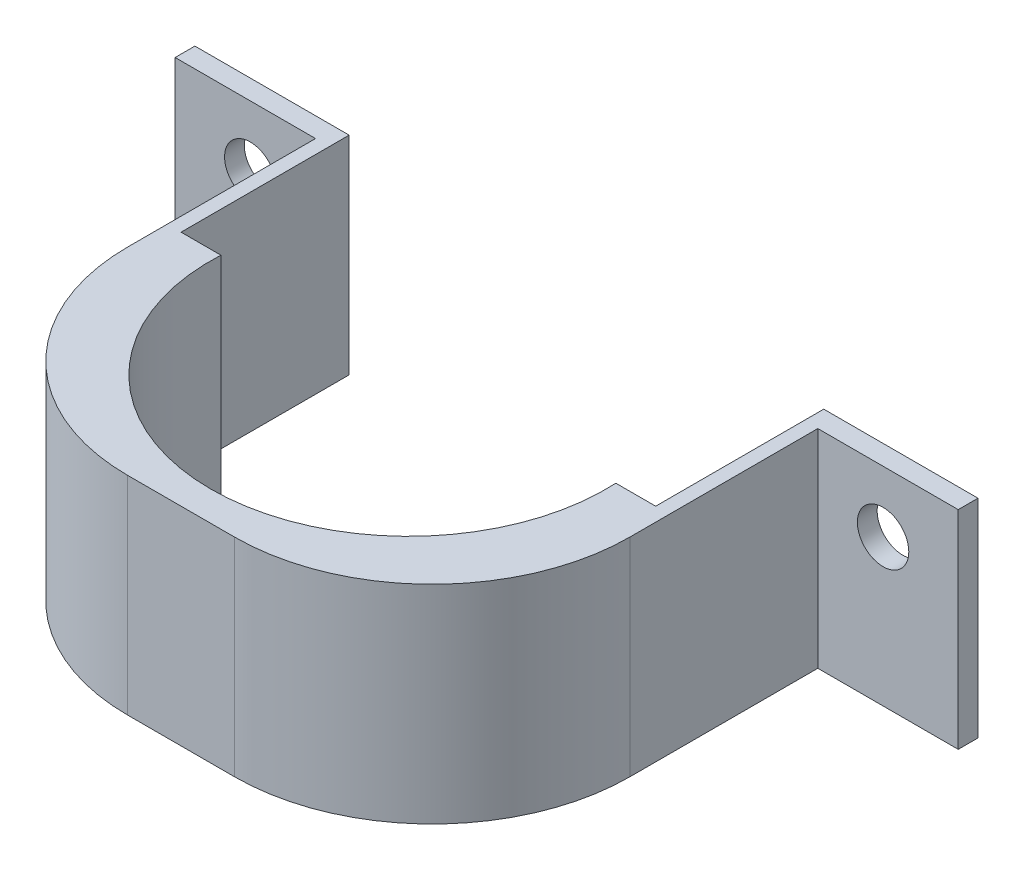
from build123d import *

# Parameters (mm, degrees)
SKETCH1_W           = 100.584
SKETCH1_H           = 26.67
SKETCH1_R           = 3.302
BOSS_EXTRUDE1_DEPTH = 2.54
SKETCH2_W           = 64.516
SKETCH2_H           = 26.67
BOSS_EXTRUDE2_DEPTH = 49.53
CUT_EXTRUDE1_REACH  = 28.67
FILLET1_R           = 25.4


with BuildPart() as part:
    # Sketch1 → Boss-Extrude1 (new body)
    with BuildSketch(Plane.XY):
        with Locations((-0.466217893, 3.598360719)):
            Rectangle(SKETCH1_W, SKETCH1_H)
        with Locations((-41.106217893, 9.059360719)):
            Circle(SKETCH1_R, mode=Mode.SUBTRACT)
        with Locations((40.173782107, 9.059360719)):
            Circle(SKETCH1_R, mode=Mode.SUBTRACT)
    extrude(amount=BOSS_EXTRUDE1_DEPTH)

    # Sketch2 → Boss-Extrude2 (add)
    with BuildSketch(Plane.XY.offset(2.54)):
        with Locations((-0.466217893, 3.598360719)):
            Rectangle(SKETCH2_W, SKETCH2_H)
    extrude(amount=BOSS_EXTRUDE2_DEPTH)

    # Sketch5 → Cut-Extrude1 (cut, up to next)
    with BuildSketch(Plane.XZ.offset(9.736639281), mode=Mode.PRIVATE) as cut_extrude1_sk1:
        with BuildLine():
            ThreePointArc((24.933782107, 22.86), (-1.101416548, 48.252056291), (-25.834448025, 21.59))
            Line((-25.834448025, 21.59), (24.902012238, 21.59))
            ThreePointArc((24.902012238, 21.59), (24.925838398, 22.224801345), (24.933782107, 22.86))
        make_face()
    cut_extrude1_tool1 = extrude(cut_extrude1_sk1.sketch, amount=-CUT_EXTRUDE1_REACH, mode=Mode.PRIVATE) & part.part
    add(cut_extrude1_tool1.solids().sort_by_distance((-0.466218, -9.736639, 32.957158))[0], mode=Mode.SUBTRACT)
    # Sketch5 → Cut-Extrude1 (cut, up to next)
    with BuildSketch(Plane.XZ.offset(9.736639281), mode=Mode.PRIVATE) as cut_extrude1_sk2:
        with BuildLine():
            ThreePointArc((-25.834448025, 21.59), (-21.643974867, 8.836355339), (-11.53782121, 0))
            Line((-11.53782121, 0), (10.605385423, 0))
            ThreePointArc((10.605385423, 0), (20.71153908, 8.836355339), (24.902012238, 21.59))
            Line((24.902012238, 21.59), (-25.834448025, 21.59))
        make_face()
    cut_extrude1_tool2 = extrude(cut_extrude1_sk2.sketch, amount=-CUT_EXTRUDE1_REACH, mode=Mode.PRIVATE) & part.part
    add(cut_extrude1_tool2.solids().sort_by_distance((-0.466218, -9.736639, 11.906571))[0], mode=Mode.SUBTRACT)
    # Sketch5 → Cut-Extrude1 (cut, up to next)
    with BuildSketch(Plane.XZ.offset(9.736639281), mode=Mode.PRIVATE) as cut_extrude1_sk3:
        with BuildLine():
            Line((-30.946217893, 21.59), (-30.946217893, 0))
            Line((-30.946217893, 0), (-11.53782121, 0))
            ThreePointArc((-11.53782121, 0), (-21.643974867, 8.836355339), (-25.834448025, 21.59))
            Line((-25.834448025, 21.59), (-30.946217893, 21.59))
        make_face()
    cut_extrude1_tool3 = extrude(cut_extrude1_sk3.sketch, amount=-CUT_EXTRUDE1_REACH, mode=Mode.PRIVATE) & part.part
    add(cut_extrude1_tool3.solids().sort_by_distance((-25.424083, -9.736639, 8.295091))[0], mode=Mode.SUBTRACT)
    # Sketch5 → Cut-Extrude1 (cut, up to next)
    with BuildSketch(Plane.XZ.offset(9.736639281), mode=Mode.PRIVATE) as cut_extrude1_sk4:
        with BuildLine():
            ThreePointArc((24.902012238, 21.59), (20.71153908, 8.836355339), (10.605385423, 0))
            Line((10.605385423, 0), (30.013782107, 0))
            Line((30.013782107, 0), (30.013782107, 21.59))
            Line((30.013782107, 21.59), (24.902012238, 21.59))
        make_face()
    cut_extrude1_tool4 = extrude(cut_extrude1_sk4.sketch, amount=-CUT_EXTRUDE1_REACH, mode=Mode.PRIVATE) & part.part
    add(cut_extrude1_tool4.solids().sort_by_distance((24.491648, -9.736639, 8.295091))[0], mode=Mode.SUBTRACT)

    # Fillet1
    fillet1_edges = [part.edges().sort_by_distance(p)[0] for p in [
        (-32.724217893, 3.598360719, 52.07),
        (31.791782107, 3.598360719, 52.07),
    ]]
    fillet(fillet1_edges, radius=FILLET1_R)


solid = part.part
